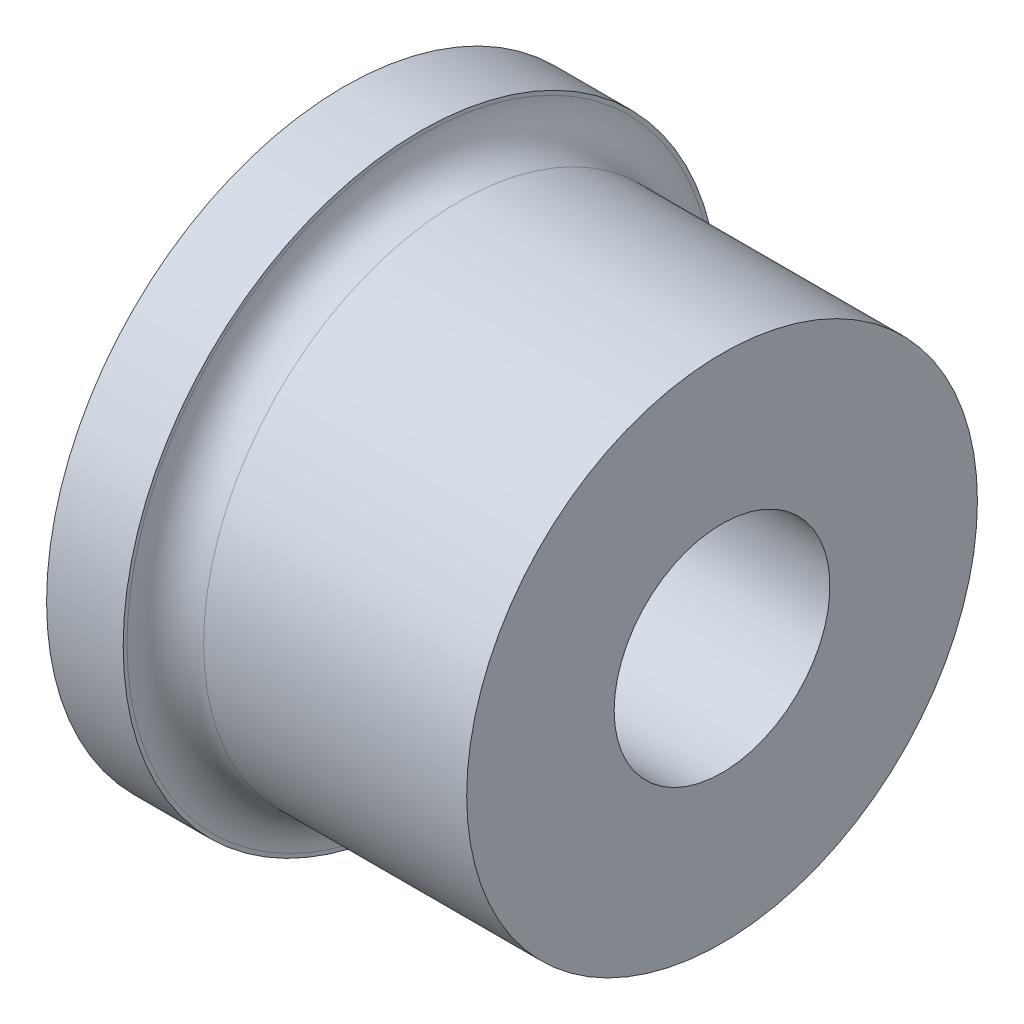
from build123d import *


with BuildPart() as part:
    # Sketch1 → Revolve1 (revolve)
    with BuildSketch(Plane(origin=(0, 0, 0), x_dir=(1, 0, 0), z_dir=(0, 1, 0))):
        with BuildLine():
            Line((-14.8, 11.65), (-14.8, 3.15))
            ThreePointArc((-14.8, 3.15), (-15.239339828, 2.089339828), (-16.3, 1.65))
            Line((-16.3, 1.65), (-20.8, 1.65))
            Line((-20.8, 1.65), (-21.8, 1.09375))
            Line((-21.8, 1.09375), (-21.8, 0.79375))
            Line((-21.8, 0.79375), (-9.8, 0.79375))
            Line((-9.8, 0.79375), (-9.8, 4.225))
            Line((-9.8, 4.225), (0, 4.225))
            Line((0, 4.225), (0, 10))
            Line((0, 10), (-10.3, 10))
            ThreePointArc((-10.3, 10), (-11.360660172, 10.439339828), (-11.8, 11.5))
            Line((-11.8, 11.5), (-11.8, 11.65))
            Line((-11.8, 11.65), (-14.8, 11.65))
        make_face()
    revolve(axis=Axis((-74.867571618, 0, 0), (1, 0, 0)))


solid = part.part
